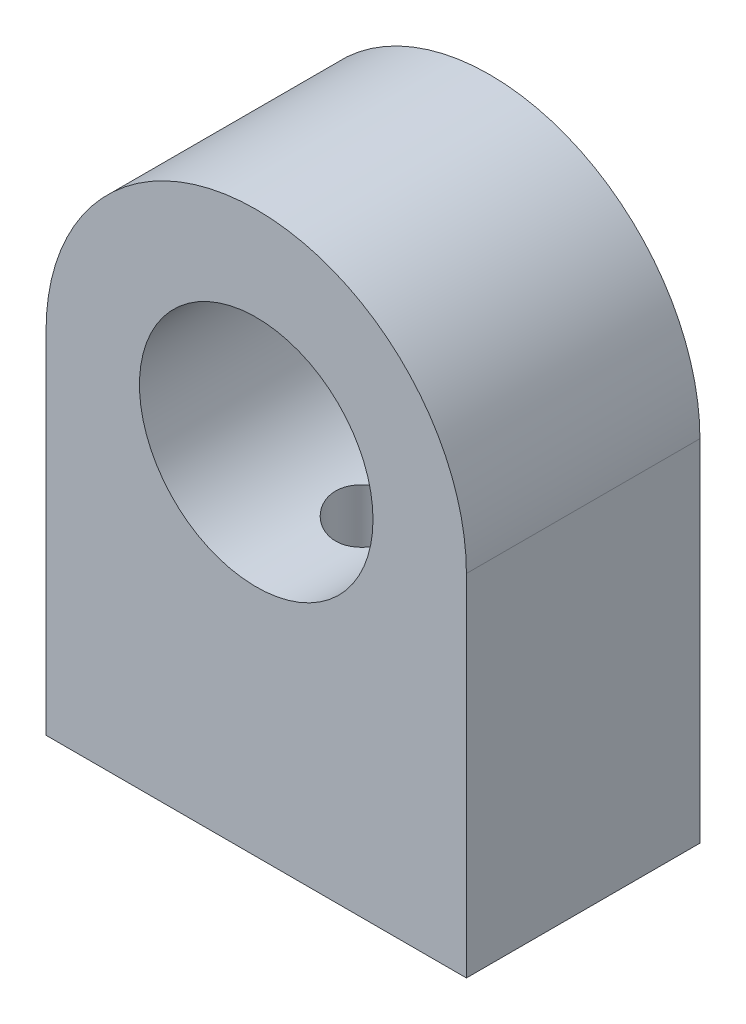
from build123d import *

# Parameters (mm, degrees)
SKETCH1_R           = 3.175
BOSS_EXTRUDE1_DEPTH = 6.35
SKETCH2_R           = 1.016
CUT_EXTRUDE1_DEPTH  = 9.144


with BuildPart() as part:
    # Sketch1 → Boss-Extrude1 (new body)
    with BuildSketch(Plane.XY):
        with BuildLine():
            Line((-5.715, -9.525), (5.715, -9.525))
            Line((5.715, -9.525), (5.715, 0))
            ThreePointArc((5.715, 0), (0, 5.715), (-5.715, 0))
            Line((-5.715, 0), (-5.715, -9.525))
        make_face()
        Circle(SKETCH1_R, mode=Mode.SUBTRACT)
    extrude(amount=BOSS_EXTRUDE1_DEPTH)

    # Sketch2 → Cut-Extrude1 (cut)
    with BuildSketch(Plane.XZ.offset(9.525)):
        with Locations((0, 3.175)):
            Circle(SKETCH2_R)
    extrude(amount=-CUT_EXTRUDE1_DEPTH, mode=Mode.SUBTRACT)


solid = part.part
